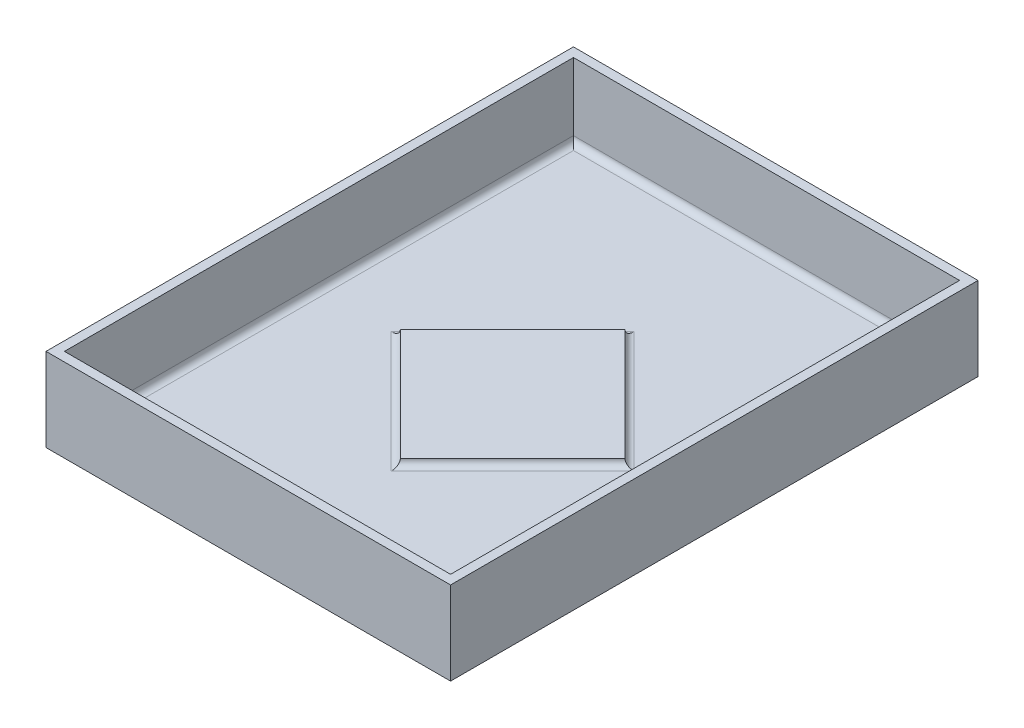
from build123d import *

# Parameters (mm, degrees)
SKETCH2_W           = 439.1
SKETCH2_H           = 572.45
SKETCH2_W_2         = 419.1
SKETCH2_H_2         = 552.45
BOSS_EXTRUDE1_DEPTH = 80.42
BOSS_EXTRUDE2_DEPTH = 7.16
SKETCH4_W           = 439.1
SKETCH4_H           = 572.45
BOSS_EXTRUDE3_DEPTH = 10
FILLET1_R           = 7


with BuildPart() as part:
    # Sketch2 → Boss-Extrude1 (new body)
    with BuildSketch(Plane(origin=(0, 0, 0), x_dir=(1, 0, 0), z_dir=(0, 1, 0))):
        with Locations((209.55, 276.225)):
            Rectangle(SKETCH2_W, SKETCH2_H)
        with Locations((209.55, 276.225)):
            Rectangle(SKETCH2_W_2, SKETCH2_H_2, mode=Mode.SUBTRACT)
    extrude(amount=BOSS_EXTRUDE1_DEPTH)



with BuildPart() as body_2:
    # Sketch3 → Boss-Extrude2 (new body)
    with BuildSketch(Plane(origin=(0, 0, 0), x_dir=(1, 0, 0), z_dir=(0, 1, 0))):
        Polygon((88.316542366, 276.225), (209.55, 154.991542366), (331.455559866, 276.897102232), (210.222102232, 398.130559866), align=None)
    extrude(amount=BOSS_EXTRUDE2_DEPTH)


with BuildPart() as part_1:
    add(part.part)

    add(body_2.part)  # Boss-Extrude3 merges body 2
    # Sketch4 → Boss-Extrude3 (add)
    with BuildSketch(Plane(origin=(0, 0, 0), x_dir=(1, 0, 0), z_dir=(0, 1, 0))):
        with Locations((209.55, 276.225)):
            Rectangle(SKETCH4_W, SKETCH4_H)
    extrude(amount=-BOSS_EXTRUDE3_DEPTH)

    # Fillet1
    fillet1_edges = [part_1.edges().sort_by_distance(p)[0] for p in [
        (270.502779933, 0, -215.944322299),
        (270.838831049, 0, -337.513831049),
        (149.269322299, 0, -337.177779933),
        (148.933271183, 0, -215.608271183),
        (419.1, 0, -276.225),
        (209.55, 0, 0),
        (0, 0, -276.225),
        (209.55, 0, -552.45),
    ]]
    fillet(fillet1_edges, radius=FILLET1_R)


solid = part_1.part
